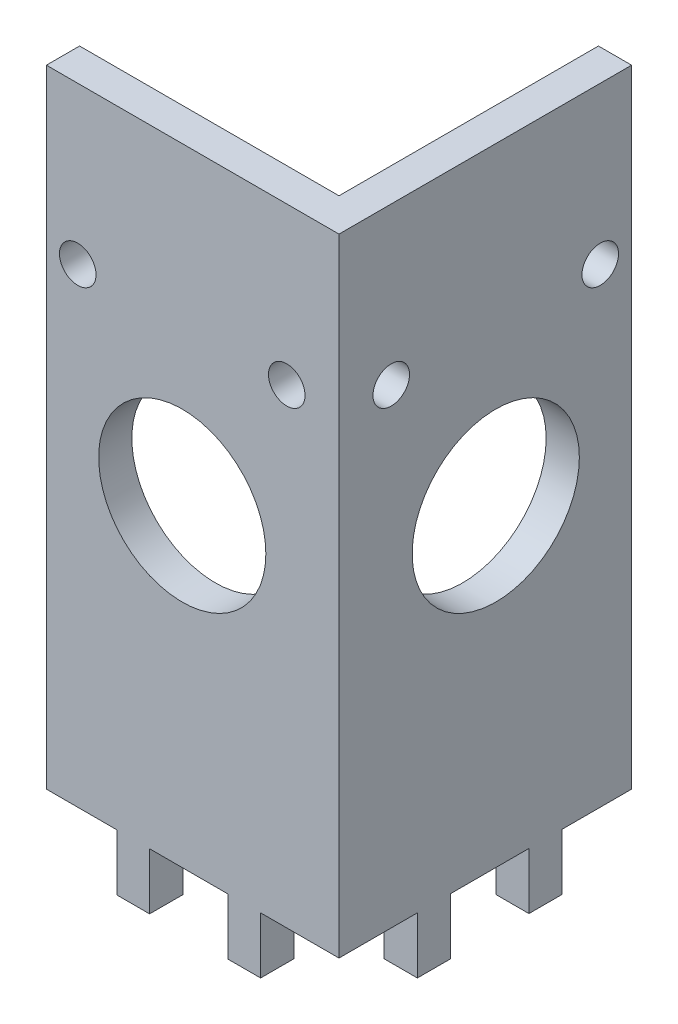
from build123d import *

# Parameters (mm, degrees)
SKETCH1_W           = 24.825
SKETCH1_H           = 3.175
SKETCH1_W_2         = 3.175
SKETCH1_H_2         = 24.825
BOSS_EXTRUDE1_DEPTH = 60
SKETCH2_W           = 3.125
SKETCH2_H           = 5.4
BOSS_EXTRUDE4_DEPTH = 3.175
SKETCH4_R           = 8
CUT_EXTRUDE1_DEPTH  = 3.175
SKETCH3_R           = 8
CUT_EXTRUDE2_DEPTH  = 3.175
SKETCH5_W           = 3.175
SKETCH5_H           = 5.4
BOSS_EXTRUDE5_DEPTH = 3.175
SKETCH6_R           = 1.75
CUT_EXTRUDE3_DEPTH  = 10
SKETCH7_R           = 1.75
CUT_EXTRUDE4_DEPTH  = 10


with BuildPart() as part:
    # Sketch1 → Boss-Extrude1 (new body)
    with BuildSketch(Plane(origin=(0, 0, 0), x_dir=(1, 0, 0), z_dir=(0, 1, 0))):
        with Locations((-38.0875, 24.0875)):
            Rectangle(SKETCH1_W, SKETCH1_H)
        with Locations((-24.0875, 24.0875)):
            Rectangle(SKETCH1_W_2, SKETCH1_H)
        with Locations((-24.0875, 38.0875)):
            Rectangle(SKETCH1_W_2, SKETCH1_H_2)
    extrude(amount=BOSS_EXTRUDE1_DEPTH)

    # Sketch2 → Boss-Extrude4 (add)
    with BuildSketch(Plane.XY.offset(-22.5)):
        with Locations((-42.1875, -2.7)):
            Rectangle(SKETCH2_W, SKETCH2_H)
        with Locations((-31.5625, -2.7)):
            Rectangle(SKETCH2_W, SKETCH2_H)
    extrude(amount=-BOSS_EXTRUDE4_DEPTH)

    # Sketch4 → Cut-Extrude1 (cut)
    with BuildSketch(Plane.XY.offset(-22.5)):
        with Locations((-37.5, 30)):
            Circle(SKETCH4_R)
    extrude(amount=-CUT_EXTRUDE1_DEPTH, mode=Mode.SUBTRACT)

    # Sketch3 → Cut-Extrude2 (cut)
    with BuildSketch(Plane(origin=(-22.5, 0, 0), x_dir=(0, 0, -1), z_dir=(1, 0, 0))):
        with Locations((37.5, 30)):
            Circle(SKETCH3_R)
    extrude(amount=-CUT_EXTRUDE2_DEPTH, mode=Mode.SUBTRACT)

    # Sketch5 → Boss-Extrude5 (add)
    with BuildSketch(Plane(origin=(-22.5, 0, 0), x_dir=(0, 0, -1), z_dir=(1, 0, 0))):
        with Locations((42.2625, -2.7)):
            Rectangle(SKETCH5_W, SKETCH5_H)
        with Locations((31.5875, -2.7)):
            Rectangle(SKETCH5_W, SKETCH5_H)
    extrude(amount=-BOSS_EXTRUDE5_DEPTH)

    # Sketch6 → Cut-Extrude3 (cut)
    with BuildSketch(Plane.XY.offset(-22.5)):
        with Locations((-47.5, 45)):
            Circle(SKETCH6_R)
        with Locations((-27.5, 45)):
            Circle(SKETCH6_R)
    extrude(amount=-CUT_EXTRUDE3_DEPTH, mode=Mode.SUBTRACT)

    # Sketch7 → Cut-Extrude4 (cut)
    with BuildSketch(Plane(origin=(-22.5, 0, 0), x_dir=(0, 0, -1), z_dir=(1, 0, 0))):
        with Locations((47.5, 45)):
            Circle(SKETCH7_R)
        with Locations((27.5, 45)):
            Circle(SKETCH7_R)
    extrude(amount=-CUT_EXTRUDE4_DEPTH, mode=Mode.SUBTRACT)


solid = part.part
